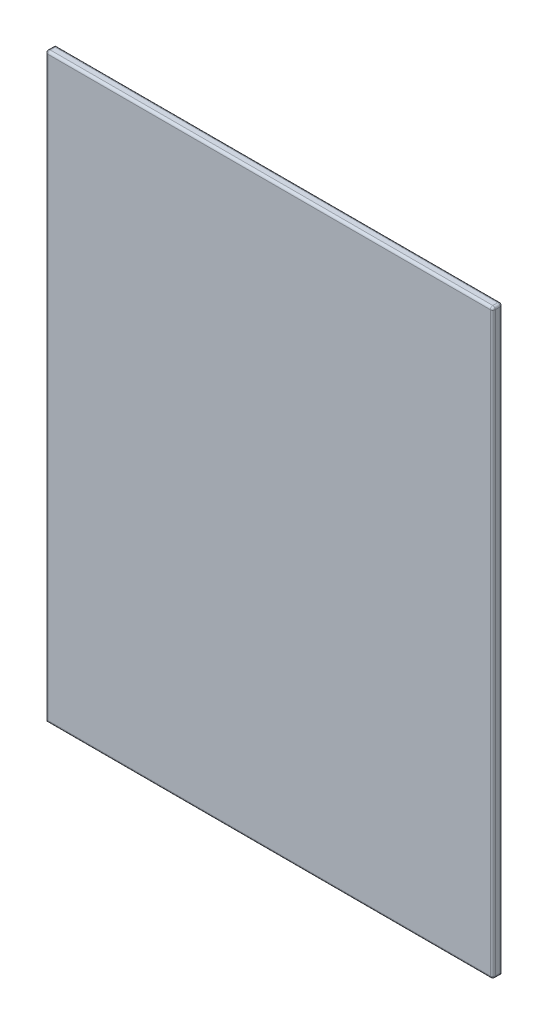
from build123d import *

# Parameters (mm, degrees)
SKETCH1_W           = 915
SKETCH1_H           = 1190
BOSS_EXTRUDE1_DEPTH = 20
FILLET1_R           = 5


with BuildPart() as part:
    # Sketch1 → Boss-Extrude1 (new body)
    with BuildSketch(Plane.XY):
        Rectangle(SKETCH1_W, SKETCH1_H)
    extrude(amount=BOSS_EXTRUDE1_DEPTH)

    # Fillet1
    fillet1_edges = [part.edges().sort_by_distance(p)[0] for p in [
        (-457.5, 0, 20),
        (0, -595, 20),
        (457.5, 0, 20),
        (0, 595, 0),
        (457.5, 0, 0),
        (457.5, -595, 10),
        (-457.5, 595, 10),
        (457.5, 595, 10),
        (0, 595, 20),
    ]]
    fillet(fillet1_edges, radius=FILLET1_R)


solid = part.part
